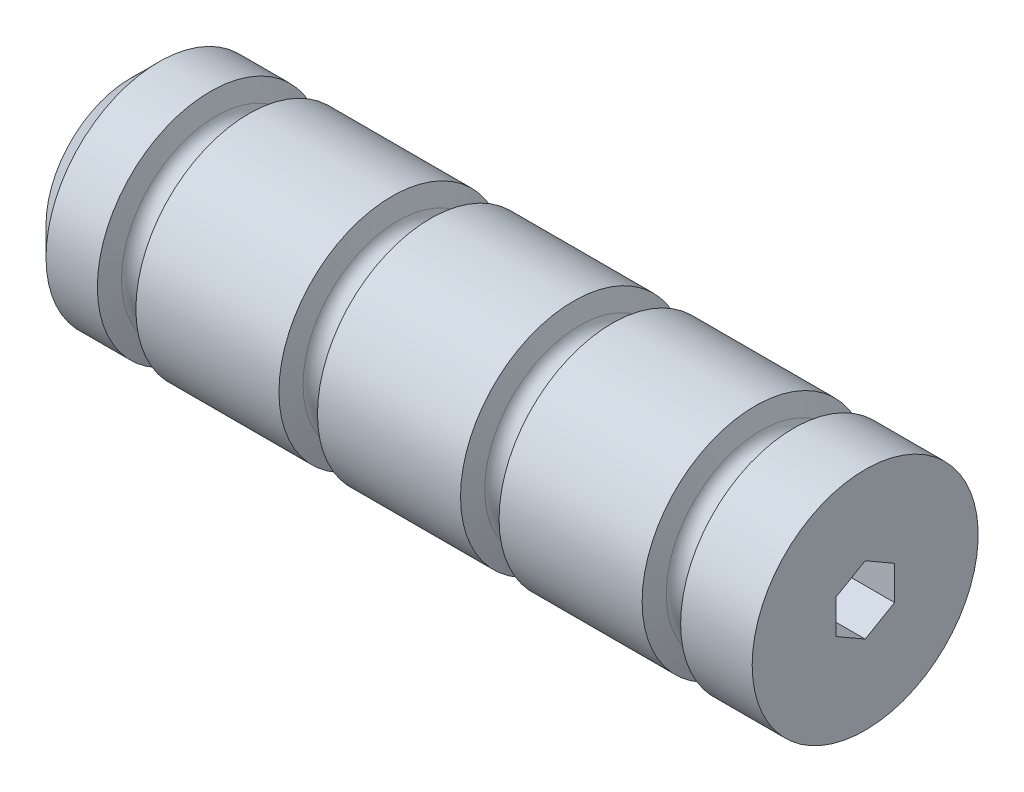
from build123d import *

# Parameters (mm, degrees)
CUT_EXTRUDE1_DEPTH = 166.1


with BuildPart() as part:
    # Sketch1 → Revolve1 (revolve)
    with BuildSketch(Plane.XY):
        Polygon((0, 0), (0, 25.4), (-158.75, 25.4), (-165.1, 19.05), (-165.1, 0), align=None)
    revolve(axis=Axis((0, 0, 0), (1, 0, 0)))

    # Sketch2 → Cut-Revolve1 (revolve, cut)
    with BuildSketch(Plane.XY):
        with BuildLine():
            Line((-16.080560659, 25.4), (-17.382662967, 21.270259087))
            ThreePointArc((-17.382662967, 21.270259087), (-20.410714286, 19.05), (-23.438765604, 21.270259087))
            Line((-23.438765604, 21.270259087), (-24.740867913, 25.4))
            Line((-24.740867913, 25.4), (-16.080560659, 25.4))
        make_face()
        with BuildLine():
            Line((-56.90198923, 25.4), (-58.204091539, 21.270259087))
            ThreePointArc((-58.204091539, 21.270259087), (-61.232142857, 19.05), (-64.260194176, 21.270259087))
            Line((-64.260194176, 21.270259087), (-65.562296484, 25.4))
            Line((-65.562296484, 25.4), (-56.90198923, 25.4))
        make_face()
        with BuildLine():
            Line((-97.723417802, 25.4), (-99.02552011, 21.270259087))
            ThreePointArc((-99.02552011, 21.270259087), (-102.053571429, 19.05), (-105.081622747, 21.270259087))
            Line((-105.081622747, 21.270259087), (-106.383725056, 25.4))
            Line((-106.383725056, 25.4), (-97.723417802, 25.4))
        make_face()
        with BuildLine():
            Line((-138.544846373, 25.4), (-139.846948681, 21.270259087))
            ThreePointArc((-139.846948681, 21.270259087), (-142.875, 19.05), (-145.903051319, 21.270259087))
            Line((-145.903051319, 21.270259087), (-147.205153627, 25.4))
            Line((-147.205153627, 25.4), (-138.544846373, 25.4))
        make_face()
    revolve(axis=Axis((0, 0, 0), (1, 0, 0)), mode=Mode.SUBTRACT)

    # Sketch3 → Cut-Extrude1 (cut, through all)
    with BuildSketch(Plane(origin=(0, 0, 0), x_dir=(0, 0, -1), z_dir=(1, 0, 0))):
        Polygon((0, 7.625642355), (-6.604, 3.812821178), (-6.604, -3.812821178), (0, -7.625642355), (6.604, -3.812821178), (6.604, 3.812821178), align=None)
    extrude(amount=-CUT_EXTRUDE1_DEPTH, mode=Mode.SUBTRACT)


solid = part.part
